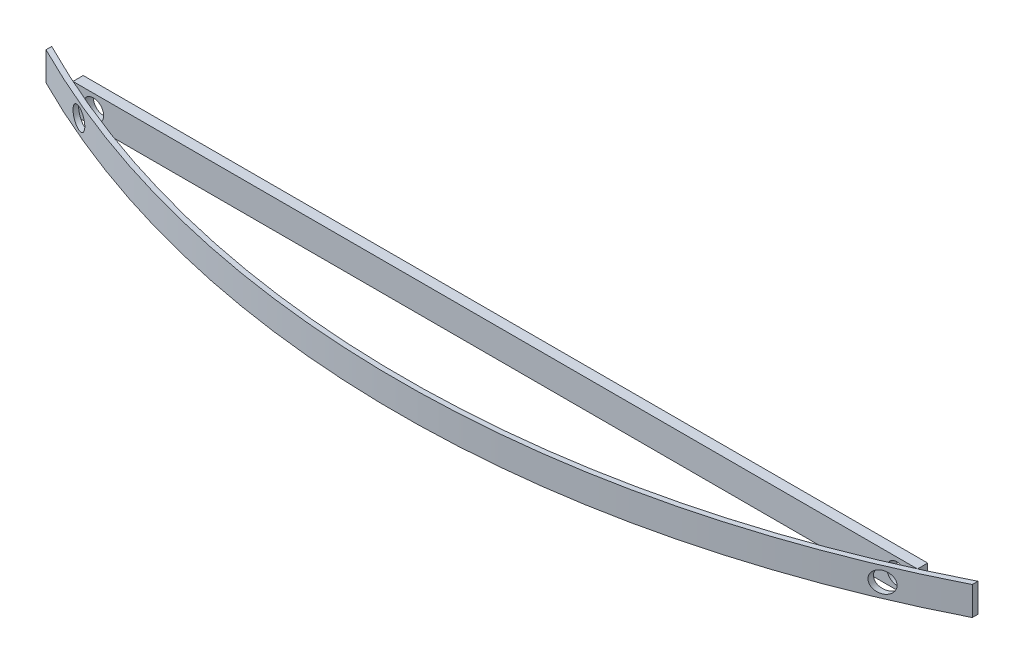
from build123d import *

# Parameters (mm, degrees)
SKETCH1_W           = 3930
SKETCH1_H           = 140
BOSS_EXTRUDE1_DEPTH = 50
SKETCH2_R           = 50
CUT_EXTRUDE1_DEPTH  = 50
SKETCH3_W           = 100
SKETCH3_H           = 140
BOSS_EXTRUDE2_DEPTH = 50
SKETCH4_R           = 50
CUT_EXTRUDE2_DEPTH  = 51
BOSS_EXTRUDE3_DEPTH = 140
SKETCH6_R           = 50
CUT_EXTRUDE3_DEPTH  = 522.344874719


with BuildPart() as part:
    # Sketch1 → Boss-Extrude1 (new body)
    with BuildSketch(Plane.XY):
        with Locations((1965, 70)):
            Rectangle(SKETCH1_W, SKETCH1_H)
    extrude(amount=BOSS_EXTRUDE1_DEPTH)

    # Sketch2 → Cut-Extrude1 (cut)
    with BuildSketch(Plane.XY.offset(50)):
        with Locations((3930, 70)):
            Circle(SKETCH2_R)
        with Locations((0, 70)):
            Circle(SKETCH2_R)
    extrude(amount=-CUT_EXTRUDE1_DEPTH, mode=Mode.SUBTRACT)

    # Sketch3 → Boss-Extrude2 (add, through all)
    with BuildSketch(Plane(origin=(0, 0, 0), x_dir=(-1, 0, 0), z_dir=(0, 0, -1))):
        with Locations((-3980, 70)):
            Rectangle(SKETCH3_W, SKETCH3_H)
        with Locations((50, 70)):
            Rectangle(SKETCH3_W, SKETCH3_H)
    extrude(amount=-BOSS_EXTRUDE2_DEPTH)

    # Sketch4 → Cut-Extrude2 (cut, through all)
    with BuildSketch(Plane(origin=(0, 0, 0), x_dir=(-1, 0, 0), z_dir=(0, 0, -1))):
        with Locations((0, 70)):
            Circle(SKETCH4_R)
        with Locations((-3930, 70)):
            Circle(SKETCH4_R)
    extrude(amount=-CUT_EXTRUDE2_DEPTH, mode=Mode.SUBTRACT)


with BuildPart() as body_2:
    # Sketch5 → Boss-Extrude3 (new body, through all)
    with BuildSketch(Plane.XZ):
        with BuildLine():
            Line((-300, -46.10254567), (-300, -18.078239305))
            ThreePointArc((-300, -18.078239305), (-205.637820717, 28.337422294), (-110.325, 72.768275626))
            ThreePointArc((-110.325, 72.768275626), (1965, 521.344874719), (4040.325, 72.768275626))
            ThreePointArc((4040.325, 72.768275626), (4135.637820717, 28.337422294), (4230, -18.078239305))
            Line((4230, -18.078239305), (4230, -46.10254567))
            ThreePointArc((4230, -46.10254567), (4130.533173337, 3.0583197), (4030, 50))
            ThreePointArc((4030, 50), (1965, 496.344874719), (-100, 50))
            ThreePointArc((-100, 50), (-200.533173337, 3.0583197), (-300, -46.10254567))
        make_face()
    extrude(amount=-BOSS_EXTRUDE3_DEPTH)

    # Sketch6 → Cut-Extrude3 (cut, through all)
    with BuildSketch(Plane(origin=(0, 0, 0), x_dir=(-1, 0, 0), z_dir=(0, 0, -1))):
        with Locations((-3930, 70)):
            Circle(SKETCH6_R)
        with Locations((0, 70)):
            Circle(SKETCH6_R)
    extrude(amount=-CUT_EXTRUDE3_DEPTH, mode=Mode.SUBTRACT)


solid = Compound([part.part, body_2.part])
